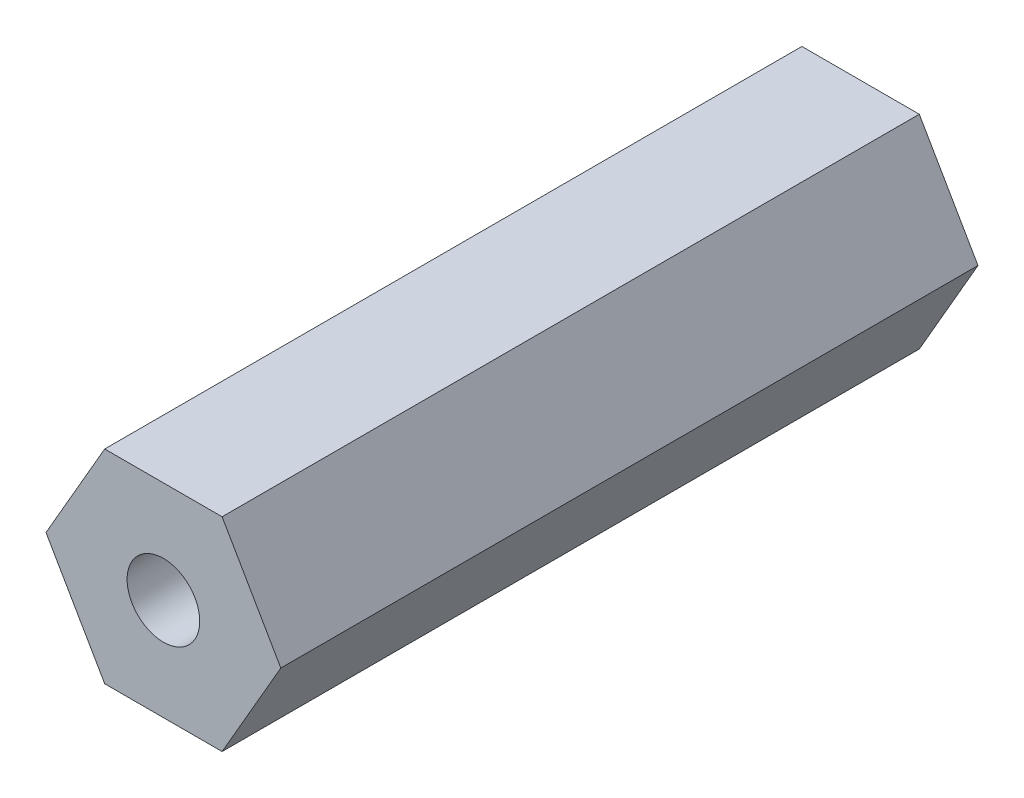
from build123d import *

# Parameters (mm, degrees)
EXTRUDE_1_DEPTH        = 24
HOLE_WIZARD_M3_1_D     = 2.5
HOLE_WIZARD_M3_1_DEPTH = 3.9
HOLE_WIZARD_M3_1_TIP   = 0.751075774
HOLE_WIZARD_M3_2_D     = 2.5
HOLE_WIZARD_M3_2_DEPTH = 3.9
HOLE_WIZARD_M3_2_TIP   = 0.751075774


with BuildPart() as part:
    # 草图1 → 凸台-拉伸1 (new body)
    with BuildSketch(Plane.XY):
        Polygon((4.041451884, 0), (2.020725942, 3.5), (-2.020725942, 3.5), (-4.041451884, 0), (-2.020725942, -3.5), (2.020725942, -3.5), align=None)
    extrude(amount=EXTRUDE_1_DEPTH)

    # M3 螺纹孔1
    with Locations(Plane(origin=(0, 0, 0), x_dir=(-1, 0, 0), z_dir=(0, 0, -1))):
        with Locations((0, 0)):
            Hole(HOLE_WIZARD_M3_1_D / 2, depth=HOLE_WIZARD_M3_1_DEPTH)
            with Locations((0, 0, -(HOLE_WIZARD_M3_1_DEPTH + HOLE_WIZARD_M3_1_TIP / 2))):  # 118° drill point
                Cone(0, HOLE_WIZARD_M3_1_D / 2, HOLE_WIZARD_M3_1_TIP, mode=Mode.SUBTRACT)

    # M3 螺纹孔2
    with Locations(Plane.XY.offset(24)):
        with Locations((0, 0)):
            Hole(HOLE_WIZARD_M3_2_D / 2, depth=HOLE_WIZARD_M3_2_DEPTH)
            with Locations((0, 0, -(HOLE_WIZARD_M3_2_DEPTH + HOLE_WIZARD_M3_2_TIP / 2))):  # 118° drill point
                Cone(0, HOLE_WIZARD_M3_2_D / 2, HOLE_WIZARD_M3_2_TIP, mode=Mode.SUBTRACT)


solid = part.part
